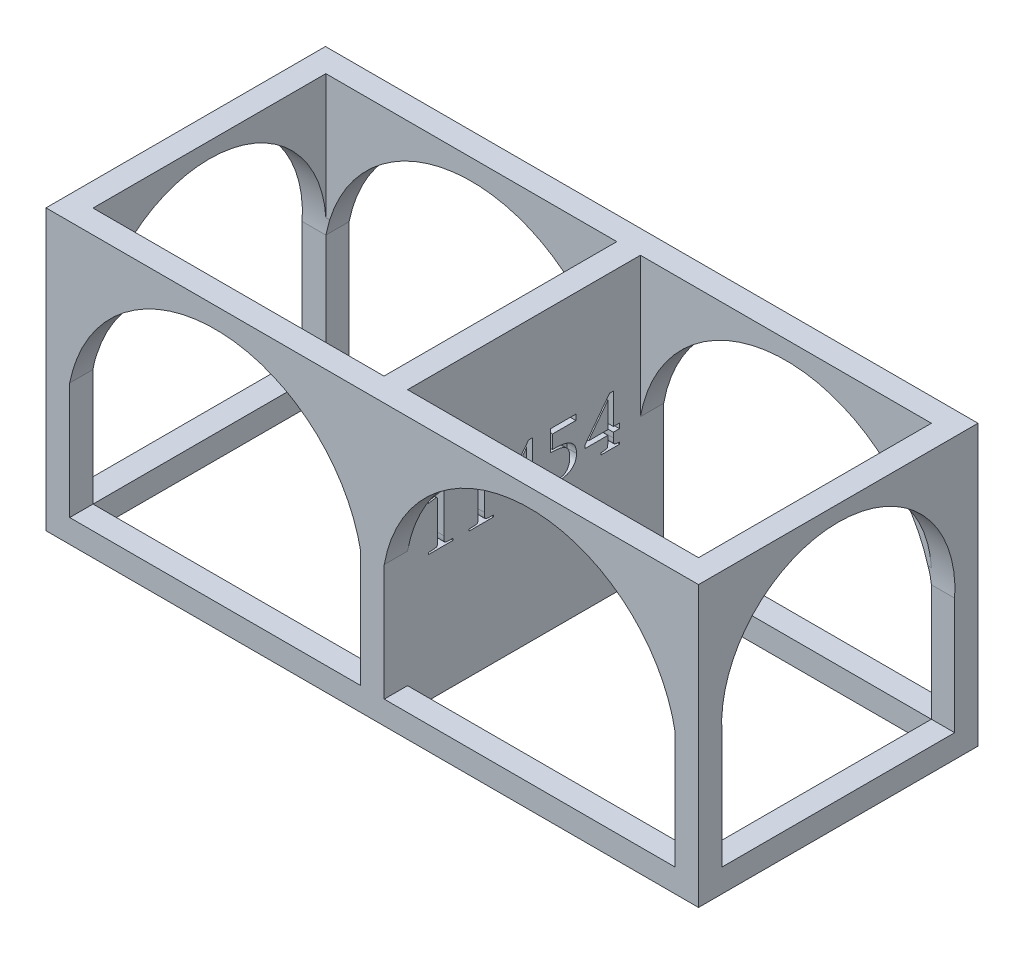
from build123d import *

# Parameters (mm, degrees)
SKETCH1_W            = 177.8
SKETCH1_H            = 6.35
BOSS_EXTRUDE1_DEPTH  = 6.35
SKETCH2_W            = 6.35
SKETCH2_H            = 76.149234203
BOSS_EXTRUDE3_DEPTH  = 6.35
SKETCH3_W            = 177.8
SKETCH3_H            = 6.35
BOSS_EXTRUDE4_DEPTH  = 6.35
SKETCH4_W            = 6.453896743
SKETCH4_H            = 76.149234203
BOSS_EXTRUDE5_DEPTH  = 6.35
SKETCH5_W            = 6.421405537
SKETCH5_H            = 76.149234203
BOSS_EXTRUDE6_DEPTH  = 76.2
SKETCH6_W            = 6.453896743
SKETCH6_H            = 6.35
BOSS_EXTRUDE7_DEPTH  = 76.2
SKETCH7_W            = 6.453896743
SKETCH7_H            = 6.35
BOSS_EXTRUDE8_DEPTH  = 76.2
SKETCH8_W            = 6.35
SKETCH8_H            = 6.35
BOSS_EXTRUDE9_DEPTH  = 76.2
SKETCH9_W            = 6.35
SKETCH9_H            = 6.35
BOSS_EXTRUDE10_DEPTH = 76.2
SKETCH10_W           = 6.453896743
SKETCH10_H           = 76.149234203
BOSS_EXTRUDE11_DEPTH = 6.35
SKETCH11_W           = 6.35
SKETCH11_H           = 76.149234203
BOSS_EXTRUDE12_DEPTH = 6.35
SKETCH12_W           = 165.323674895
SKETCH12_H           = 6.35
BOSS_EXTRUDE13_DEPTH = 6.35
SKETCH13_W           = 6.35
SKETCH13_H           = 6.35
BOSS_EXTRUDE14_DEPTH = 175.26
CUT_EXTRUDE1_DEPTH   = 2.54
SKETCH22_W           = 6.35
SKETCH22_H           = 31.75
BOSS_EXTRUDE16_DEPTH = 165.1
CUT_EXTRUDE3_DEPTH   = 165.1
CUT_EXTRUDE4_DEPTH   = 165.1
SKETCH26_W           = 6.35
SKETCH26_H           = 31.75
BOSS_EXTRUDE17_DEPTH = 165.1
CUT_EXTRUDE5_DEPTH   = 165.1
CUT_EXTRUDE6_DEPTH   = 165.1
SKETCH29_W           = 6.453896743
SKETCH29_H           = 31.75
BOSS_EXTRUDE18_DEPTH = 65.278
CUT_EXTRUDE7_DEPTH   = 65.278
SKETCH31_W           = 6.35
SKETCH31_H           = 31.75
BOSS_EXTRUDE19_DEPTH = 65.278
CUT_EXTRUDE8_DEPTH   = 65.278


with BuildPart() as part:
    # Sketch1 → Boss-Extrude1 (new body)
    with BuildSketch(Plane(origin=(0, 0, 0), x_dir=(1, 0, 0), z_dir=(0, 1, 0))):
        with Locations((88.9, -3.175)):
            Rectangle(SKETCH1_W, SKETCH1_H)
    extrude(amount=BOSS_EXTRUDE1_DEPTH)

    # Sketch2 → Boss-Extrude3 (add)
    with BuildSketch(Plane(origin=(0, 0, 0), x_dir=(-1, 0, 0), z_dir=(0, -1, 0))):
        with Locations((-174.625, -38.074617102)):
            Rectangle(SKETCH2_W, SKETCH2_H)
    extrude(amount=-BOSS_EXTRUDE3_DEPTH)

    # Sketch3 → Boss-Extrude4 (add)
    with BuildSketch(Plane.XZ):
        with Locations((88.9, 72.974234203)):
            Rectangle(SKETCH3_W, SKETCH3_H)
    extrude(amount=-BOSS_EXTRUDE4_DEPTH)

    # Sketch4 → Boss-Extrude5 (add)
    with BuildSketch(Plane(origin=(0, 0, 0), x_dir=(-1, 0, 0), z_dir=(0, -1, 0))):
        with Locations((-3.226948372, -38.074617102)):
            Rectangle(SKETCH4_W, SKETCH4_H)
    extrude(amount=-BOSS_EXTRUDE5_DEPTH)

    # Sketch5 → Boss-Extrude6 (add)
    with BuildSketch(Plane(origin=(0, 0, 0), x_dir=(-1, 0, 0), z_dir=(0, -1, 0))):
        with Locations((-88.951948372, -38.074617102)):
            Rectangle(SKETCH5_W, SKETCH5_H)
    extrude(amount=-BOSS_EXTRUDE6_DEPTH)

    # Sketch6 → Boss-Extrude7 (add)
    with BuildSketch(Plane(origin=(0, 0, 0), x_dir=(-1, 0, 0), z_dir=(0, -1, 0))):
        with Locations((-3.226948372, -72.974234203)):
            Rectangle(SKETCH6_W, SKETCH6_H)
    extrude(amount=-BOSS_EXTRUDE7_DEPTH)

    # Sketch7 → Boss-Extrude8 (add)
    with BuildSketch(Plane(origin=(0, 0, 0), x_dir=(-1, 0, 0), z_dir=(0, -1, 0))):
        with Locations((-3.226948372, -3.175)):
            Rectangle(SKETCH7_W, SKETCH7_H)
    extrude(amount=-BOSS_EXTRUDE8_DEPTH)

    # Sketch8 → Boss-Extrude9 (add)
    with BuildSketch(Plane(origin=(0, 0, 0), x_dir=(-1, 0, 0), z_dir=(0, -1, 0))):
        with Locations((-174.625, -3.175)):
            Rectangle(SKETCH8_W, SKETCH8_H)
    extrude(amount=-BOSS_EXTRUDE9_DEPTH)

    # Sketch9 → Boss-Extrude10 (add)
    with BuildSketch(Plane(origin=(0, 0, 0), x_dir=(-1, 0, 0), z_dir=(0, -1, 0))):
        with Locations((-174.625, -72.974234203)):
            Rectangle(SKETCH9_W, SKETCH9_H)
    extrude(amount=-BOSS_EXTRUDE10_DEPTH)

    # Sketch10 → Boss-Extrude11 (add)
    with BuildSketch(Plane(origin=(0, 76.2, 0), x_dir=(1, 0, 0), z_dir=(0, 1, 0))):
        with Locations((3.226948372, -38.074617102)):
            Rectangle(SKETCH10_W, SKETCH10_H)
    extrude(amount=-BOSS_EXTRUDE11_DEPTH)

    # Sketch11 → Boss-Extrude12 (add)
    with BuildSketch(Plane(origin=(0, 76.2, 0), x_dir=(1, 0, 0), z_dir=(0, 1, 0))):
        with Locations((174.625, -38.074617102)):
            Rectangle(SKETCH11_W, SKETCH11_H)
    extrude(amount=-BOSS_EXTRUDE12_DEPTH)

    # Sketch12 → Boss-Extrude13 (add)
    with BuildSketch(Plane(origin=(0, 69.85, 0), x_dir=(-1, 0, 0), z_dir=(0, -1, 0))):
        with Locations((-89.115734191, -3.175)):
            Rectangle(SKETCH12_W, SKETCH12_H)
    extrude(amount=-BOSS_EXTRUDE13_DEPTH)

    # Sketch13 → Boss-Extrude14 (add)
    with BuildSketch(Plane.ZY):
        with Locations((72.974234203, 73.025)):
            Rectangle(SKETCH13_W, SKETCH13_H)
    extrude(amount=-BOSS_EXTRUDE14_DEPTH)

    # Sketch16 → Cut-Extrude1 (cut)
    with BuildSketch(Plane(origin=(92.16265114, 0, 0), x_dir=(0, 0, -1), z_dir=(1, 0, 0))):
        with BuildLine():
            Line((-59.914633961, 47.83491605), (-59.914633961, 36.787925866))
            add(Edge.make_bspline(
                [(-59.914633961, 36.787925866), (-59.913759787, 36.663245095), (-59.912120669, 36.429462827), (-59.896980538, 36.102264714), (-59.871643151, 35.821080582), (-59.837275502, 35.586583277), (-59.791150313, 35.39723477), (-59.736881528, 35.255133097), (-59.669883586, 35.151064291), (-59.607603225, 35.12008517), (-59.579876683, 35.106293601)],
                knots=[0, 0, 0, 0, 0.000374023, 0.000701311, 0.000982367, 0.001220574, 0.001412134, 0.00156463, 0.001678658, 0.001770156, 0.001770156, 0.001770156, 0.001770156], degree=3))
            add(Edge.make_bspline(
                [(-59.579876683, 35.106293601), (-59.392401179, 35.062488157), (-59.016424865, 34.974637698), (-58.630488719, 34.963037777), (-58.436994412, 34.957222)],
                knots=[0, 0, 0, 0, 0.000575988, 0.001155126, 0.001155126, 0.001155126, 0.001155126], degree=3))
            Line((-58.436994412, 34.957222), (-57.403954374, 34.946760835))
            Line((-57.403954374, 34.946760835), (-57.403954374, 34.444624918))
            Line((-57.403954374, 34.444624918), (-64.09909994, 34.444624918))
            Line((-64.09909994, 34.444624918), (-64.09909994, 34.946760835))
            Line((-64.09909994, 34.946760835), (-63.066059902, 34.957222))
            add(Edge.make_bspline(
                [(-63.066059902, 34.957222), (-62.872565595, 34.963037777), (-62.486629449, 34.974637698), (-62.110653135, 35.062488157), (-61.923177631, 35.106293601)],
                knots=[0, 0, 0, 0, 0.000579138, 0.001155126, 0.001155126, 0.001155126, 0.001155126], degree=3))
            add(Edge.make_bspline(
                [(-61.923177631, 35.106293601), (-61.895451089, 35.12008517), (-61.833170729, 35.151064291), (-61.766172786, 35.255133097), (-61.711904001, 35.39723477), (-61.665778812, 35.586583277), (-61.631411163, 35.821080582), (-61.606073777, 36.102264714), (-61.590933646, 36.429462827), (-61.589294527, 36.663245095), (-61.588420353, 36.787925866)],
                knots=[0, 0, 0, 0, 9.1498e-05, 0.000205526, 0.000358022, 0.000549582, 0.000787789, 0.001068845, 0.001396132, 0.001770156, 0.001770156, 0.001770156, 0.001770156], degree=3))
            Line((-61.588420353, 36.787925866), (-61.588420353, 45.279776512))
            add(Edge.make_bspline(
                [(-61.588420353, 45.279776512), (-61.58905978, 45.412300604), (-61.590234229, 45.655710533), (-61.607169163, 45.98930044), (-61.637519326, 46.258371421), (-61.676011963, 46.469249407), (-61.733690952, 46.627694028), (-61.805299758, 46.7429507), (-61.900887104, 46.819755862), (-61.975153769, 46.827027138), (-62.012097533, 46.830644215)],
                knots=[0, 0, 0, 0, 0.000397559, 0.000730205, 0.001001402, 0.001209642, 0.001371874, 0.001503888, 0.001614259, 0.001723508, 0.001723508, 0.001723508, 0.001723508], degree=3))
            add(Edge.make_bspline(
                [(-62.012097533, 46.830644215), (-62.038264027, 46.830024184), (-62.097659418, 46.828616774), (-62.197038193, 46.819719959), (-62.317608729, 46.807532713), (-62.458295729, 46.784293092), (-62.621063908, 46.763057647), (-62.802623968, 46.729397475), (-63.00631847, 46.696981341), (-63.148078908, 46.669787462), (-63.222977376, 46.655419703)],
                knots=[0, 0, 0, 0, 7.8502e-05, 0.000178193, 0.000299205, 0.000441972, 0.000605819, 0.00079156, 0.000995787, 0.001224562, 0.001224562, 0.001224562, 0.001224562], degree=3))
            Line((-63.222977376, 46.655419703), (-64.09909994, 46.495886937))
            Line((-64.09909994, 46.495886937), (-64.09909994, 46.998022855))
            Line((-64.09909994, 46.998022855), (-59.914633961, 47.83491605))
        make_face()
        with BuildLine():
            Line((-48.867643777, 47.83491605), (-48.867643777, 36.787925866))
            add(Edge.make_bspline(
                [(-48.867643777, 36.787925866), (-48.866769602, 36.663245095), (-48.865130484, 36.429462827), (-48.849990353, 36.102264714), (-48.824652967, 35.821080582), (-48.790285317, 35.586583277), (-48.744160129, 35.39723477), (-48.689891344, 35.255133097), (-48.622893401, 35.151064291), (-48.56061304, 35.12008517), (-48.532886499, 35.106293601)],
                knots=[0, 0, 0, 0, 0.000374023, 0.000701311, 0.000982367, 0.001220574, 0.001412134, 0.00156463, 0.001678658, 0.001770156, 0.001770156, 0.001770156, 0.001770156], degree=3))
            add(Edge.make_bspline(
                [(-48.532886499, 35.106293601), (-48.345410995, 35.062488157), (-47.969434681, 34.974637698), (-47.583498535, 34.963037777), (-47.390004228, 34.957222)],
                knots=[0, 0, 0, 0, 0.000575988, 0.001155126, 0.001155126, 0.001155126, 0.001155126], degree=3))
            Line((-47.390004228, 34.957222), (-46.35696419, 34.946760835))
            Line((-46.35696419, 34.946760835), (-46.35696419, 34.444624918))
            Line((-46.35696419, 34.444624918), (-53.052109756, 34.444624918))
            Line((-53.052109756, 34.444624918), (-53.052109756, 34.946760835))
            Line((-53.052109756, 34.946760835), (-52.019069717, 34.957222))
            add(Edge.make_bspline(
                [(-52.019069717, 34.957222), (-51.825575411, 34.963037777), (-51.439639264, 34.974637698), (-51.063662951, 35.062488157), (-50.876187447, 35.106293601)],
                knots=[0, 0, 0, 0, 0.000579138, 0.001155126, 0.001155126, 0.001155126, 0.001155126], degree=3))
            add(Edge.make_bspline(
                [(-50.876187447, 35.106293601), (-50.848460905, 35.12008517), (-50.786180544, 35.151064291), (-50.719182602, 35.255133097), (-50.664913817, 35.39723477), (-50.618788628, 35.586583277), (-50.584420979, 35.821080582), (-50.559083592, 36.102264714), (-50.543943461, 36.429462827), (-50.542304343, 36.663245095), (-50.541430169, 36.787925866)],
                knots=[0, 0, 0, 0, 9.1498e-05, 0.000205526, 0.000358022, 0.000549582, 0.000787789, 0.001068845, 0.001396132, 0.001770156, 0.001770156, 0.001770156, 0.001770156], degree=3))
            Line((-50.541430169, 36.787925866), (-50.541430169, 45.279776512))
            add(Edge.make_bspline(
                [(-50.541430169, 45.279776512), (-50.542069595, 45.412300604), (-50.543244045, 45.655710533), (-50.560178978, 45.98930044), (-50.590529141, 46.258371421), (-50.629021779, 46.469249407), (-50.686700768, 46.627694028), (-50.758309574, 46.7429507), (-50.85389692, 46.819755862), (-50.928163585, 46.827027138), (-50.965107349, 46.830644215)],
                knots=[0, 0, 0, 0, 0.000397559, 0.000730205, 0.001001402, 0.001209642, 0.001371874, 0.001503888, 0.001614259, 0.001723508, 0.001723508, 0.001723508, 0.001723508], degree=3))
            add(Edge.make_bspline(
                [(-50.965107349, 46.830644215), (-50.991273842, 46.830024184), (-51.050669234, 46.828616774), (-51.150048009, 46.819719959), (-51.270618545, 46.807532713), (-51.411305544, 46.784293092), (-51.574073724, 46.763057647), (-51.755633784, 46.729397475), (-51.959328286, 46.696981341), (-52.101088723, 46.669787462), (-52.175987192, 46.655419703)],
                knots=[0, 0, 0, 0, 7.8502e-05, 0.000178193, 0.000299205, 0.000441972, 0.000605819, 0.00079156, 0.000995787, 0.001224562, 0.001224562, 0.001224562, 0.001224562], degree=3))
            Line((-52.175987192, 46.655419703), (-53.052109756, 46.495886937))
            Line((-53.052109756, 46.495886937), (-53.052109756, 46.998022855))
            Line((-53.052109756, 46.998022855), (-48.867643777, 47.83491605))
        make_face()
        with BuildLine():
            Line((-37.318517675, 38.126954979), (-43.511527324, 38.126954979))
            Line((-43.511527324, 38.126954979), (-43.511527324, 39.016154))
            Line((-43.511527324, 39.016154), (-36.834688796, 47.83491605))
            Line((-36.834688796, 47.83491605), (-35.812109923, 47.83491605))
            Line((-35.812109923, 47.83491605), (-35.812109923, 39.465984093))
            Line((-35.812109923, 39.465984093), (-34.138323531, 39.465984093))
            Line((-34.138323531, 39.465984093), (-34.138323531, 38.126954979))
            Line((-34.138323531, 38.126954979), (-35.812109923, 38.126954979))
            Line((-35.812109923, 38.126954979), (-35.812109923, 36.787925866))
            add(Edge.make_bspline(
                [(-35.812109923, 36.787925866), (-35.811925803, 36.687660934), (-35.811576658, 36.497529202), (-35.800561224, 36.228073269), (-35.785341528, 35.990846704), (-35.765937635, 35.785468718), (-35.737233937, 35.612591204), (-35.704598987, 35.471402477), (-35.667206811, 35.360957906), (-35.617740037, 35.27711367), (-35.546618739, 35.213585604), (-35.450662, 35.164209137), (-35.328098398, 35.116303462), (-35.176543024, 35.077534792), (-34.998351086, 35.036357232), (-34.790693954, 35.007985812), (-34.555528369, 34.977829615), (-34.388599154, 34.964342372), (-34.300471588, 34.957222)],
                knots=[0, 0, 0, 0, 0.00030077, 0.000570348, 0.000808856, 0.001013919, 0.001188909, 0.00133417, 0.001448347, 0.001537613, 0.001622761, 0.001730465, 0.001859651, 0.002017003, 0.002199119, 0.002408097, 0.002645224, 0.002910415, 0.002910415, 0.002910415, 0.002910415], degree=3))
            Line((-34.300471588, 34.957222), (-34.138323531, 34.946760835))
            Line((-34.138323531, 34.946760835), (-34.138323531, 34.444624918))
            Line((-34.138323531, 34.444624918), (-39.159682706, 34.444624918))
            Line((-39.159682706, 34.444624918), (-39.159682706, 34.946760835))
            Line((-39.159682706, 34.946760835), (-39.002765232, 34.957222))
            add(Edge.make_bspline(
                [(-39.002765232, 34.957222), (-38.899858841, 34.964627249), (-38.705235248, 34.978632562), (-38.430622754, 35.005121311), (-38.190362897, 35.031869136), (-37.985583709, 35.066774859), (-37.815388252, 35.100849838), (-37.68039367, 35.14258918), (-37.579677722, 35.185563247), (-37.501988131, 35.235344675), (-37.455094454, 35.316015904), (-37.417617753, 35.421160561), (-37.387748913, 35.563027844), (-37.363002091, 35.73865047), (-37.342324966, 35.950711131), (-37.326748935, 36.197527443), (-37.320005996, 36.481027586), (-37.319033458, 36.681569203), (-37.318517675, 36.787925866)],
                knots=[0, 0, 0, 0, 0.000309501, 0.000585349, 0.000827669, 0.001034476, 0.001208368, 0.001348158, 0.001457031, 0.001537597, 0.00161884, 0.001730565, 0.001872684, 0.002052436, 0.002262703, 0.002511651, 0.002794211, 0.003113287, 0.003113287, 0.003113287, 0.003113287], degree=3))
            Line((-37.318517675, 36.787925866), (-37.318517675, 38.126954979))
        make_face()
        Polygon((-42.575253061, 39.465984093), (-37.318517675, 39.465984093), (-37.318517675, 46.406967035), align=None, mode=Mode.SUBTRACT)
        with BuildLine():
            Line((-30.958129387, 34.444624918), (-30.958129387, 36.620547227))
            Line((-30.958129387, 36.620547227), (-30.121236192, 36.620547227))
            Line((-30.121236192, 36.620547227), (-30.121236192, 36.403478054))
            add(Edge.make_bspline(
                [(-30.121236192, 36.403478054), (-30.120564631, 36.318876102), (-30.119275124, 36.156426499), (-30.100429889, 35.924208555), (-30.072060001, 35.712783095), (-30.033574649, 35.522997354), (-29.985740551, 35.353674702), (-29.921015233, 35.208184598), (-29.850105087, 35.080718429), (-29.760199137, 34.975601418), (-29.655500936, 34.886676314), (-29.529352334, 34.813202244), (-29.382222052, 34.751531849), (-29.215063891, 34.699353277), (-29.026589457, 34.66083959), (-28.816883314, 34.63284561), (-28.58552706, 34.614022339), (-28.423951726, 34.612692621), (-28.340222859, 34.612003557)],
                knots=[0, 0, 0, 0, 0.000253737, 0.000487217, 0.000698409, 0.000893314, 0.001067913, 0.001224852, 0.001370183, 0.001503793, 0.001637404, 0.001780482, 0.001939822, 0.002115183, 0.002304967, 0.002516159, 0.002749639, 0.003000761, 0.003000761, 0.003000761, 0.003000761], degree=3))
            add(Edge.make_bspline(
                [(-28.340222859, 34.612003557), (-28.237199735, 34.615133927), (-28.035399548, 34.62126565), (-27.741240656, 34.665836359), (-27.463579822, 34.741755291), (-27.203454229, 34.850397979), (-26.957976795, 34.986078264), (-26.731355363, 35.156164994), (-26.521735653, 35.355537201), (-26.331116162, 35.584637105), (-26.158145874, 35.837910466), (-26.00928546, 36.116260918), (-25.884529454, 36.416358643), (-25.777944794, 36.736460123), (-25.70193463, 37.080419271), (-25.644673345, 37.445479714), (-25.606246078, 37.832357139), (-25.603446615, 38.09809192), (-25.602012934, 38.23418192)],
                knots=[0, 0, 0, 0, 0.000309003, 0.000605271, 0.000890157, 0.001170397, 0.001449057, 0.001729418, 0.002018002, 0.002315019, 0.002621857, 0.002936616, 0.00326011, 0.003595887, 0.00394736, 0.00431541, 0.004704201, 0.005112321, 0.005112321, 0.005112321, 0.005112321], degree=3))
            add(Edge.make_bspline(
                [(-25.602012934, 38.23418192), (-25.605215808, 38.393887983), (-25.611397098, 38.702107842), (-25.667191224, 39.145060661), (-25.755262972, 39.55187242), (-25.877824601, 39.922762497), (-26.046243739, 40.253349079), (-26.244267012, 40.548907282), (-26.480606809, 40.807369651), (-26.758290177, 41.027752631), (-27.081941445, 41.214357106), (-27.453698102, 41.376715916), (-27.879252976, 41.510656651), (-28.358800373, 41.619385261), (-28.890996971, 41.703526281), (-29.476614431, 41.766234878), (-30.115565222, 41.801738481), (-30.559689396, 41.806702464), (-30.790750748, 41.809285041)],
                knots=[0, 0, 0, 0, 0.000478948, 0.000924332, 0.001336786, 0.001726324, 0.002092408, 0.002446392, 0.002790678, 0.003138669, 0.003505574, 0.003908406, 0.004353374, 0.004841867, 0.005382322, 0.0059689, 0.00660808, 0.007301256, 0.007301256, 0.007301256, 0.007301256], degree=3))
            Line((-30.790750748, 41.809285041), (-30.790750748, 47.500158772))
            Line((-30.790750748, 47.500158772), (-23.928226543, 47.500158772))
            Line((-23.928226543, 47.500158772), (-23.928226543, 45.99375102))
            Line((-23.928226543, 45.99375102), (-30.288614831, 45.99375102))
            Line((-30.288614831, 45.99375102), (-30.288614831, 42.311420958))
            Line((-30.288614831, 42.311420958), (-29.449106344, 42.311420958))
            add(Edge.make_bspline(
                [(-29.449106344, 42.311420958), (-29.219728242, 42.308856857), (-28.774346395, 42.303878161), (-28.129182963, 42.252843513), (-27.527735774, 42.174304361), (-26.971204277, 42.058710836), (-26.458007523, 41.914321773), (-25.988363412, 41.735999703), (-25.562392638, 41.525909255), (-25.183172135, 41.277088346), (-24.844244741, 41.00078204), (-24.555457203, 40.685050732), (-24.305469824, 40.341302036), (-24.107988338, 39.959974262), (-23.948008178, 39.549489841), (-23.841533831, 39.103275203), (-23.770421839, 38.626151765), (-23.764096759, 38.2963543), (-23.760847904, 38.126954979)],
                knots=[0, 0, 0, 0, 0.000688001, 0.001335886, 0.00194025, 0.002506508, 0.003039617, 0.003537951, 0.004011637, 0.004461376, 0.004896018, 0.005319832, 0.005741511, 0.006167346, 0.006604467, 0.007059896, 0.007540712, 0.008048509, 0.008048509, 0.008048509, 0.008048509], degree=3))
            add(Edge.make_bspline(
                [(-23.760847904, 38.126954979), (-23.764861082, 37.974186691), (-23.772713403, 37.675275052), (-23.834180758, 37.239881108), (-23.932175784, 36.828920314), (-24.074030632, 36.444157328), (-24.258343281, 36.086291908), (-24.483035059, 35.754327417), (-24.74575046, 35.445858337), (-25.049683337, 35.167161076), (-25.389128779, 34.917447349), (-25.761179285, 34.700869868), (-26.163381904, 34.517264593), (-26.596276821, 34.368167599), (-27.059850931, 34.250609427), (-27.554977424, 34.168425507), (-28.080239539, 34.117620554), (-28.440355379, 34.112498185), (-28.625289604, 34.10986764)],
                knots=[0, 0, 0, 0, 0.000458154, 0.00089644, 0.001316355, 0.001723467, 0.002123496, 0.002520994, 0.00292352, 0.003336247, 0.003755233, 0.004185391, 0.004625421, 0.005079496, 0.005557129, 0.006058453, 0.006583867, 0.00713853, 0.00713853, 0.00713853, 0.00713853], degree=3))
            add(Edge.make_bspline(
                [(-28.625289604, 34.10986764), (-28.814643828, 34.113907865), (-29.196977912, 34.122065675), (-29.776066928, 34.189161558), (-30.366353461, 34.291113689), (-30.759116199, 34.392999365), (-30.958129387, 34.444624918)],
                knots=[0, 0, 0, 0, 0.000567904, 0.001146681, 0.001746923, 0.002363472, 0.002363472, 0.002363472, 0.002363472], degree=3))
        make_face()
        with BuildLine():
            Line((-15.224537307, 38.126954979), (-21.417546955, 38.126954979))
            Line((-21.417546955, 38.126954979), (-21.417546955, 39.016154))
            Line((-21.417546955, 39.016154), (-14.740708428, 47.83491605))
            Line((-14.740708428, 47.83491605), (-13.718129554, 47.83491605))
            Line((-13.718129554, 47.83491605), (-13.718129554, 39.465984093))
            Line((-13.718129554, 39.465984093), (-12.044343163, 39.465984093))
            Line((-12.044343163, 39.465984093), (-12.044343163, 38.126954979))
            Line((-12.044343163, 38.126954979), (-13.718129554, 38.126954979))
            Line((-13.718129554, 38.126954979), (-13.718129554, 36.787925866))
            add(Edge.make_bspline(
                [(-13.718129554, 36.787925866), (-13.717945435, 36.687660934), (-13.71759629, 36.497529202), (-13.706580855, 36.228073269), (-13.691361159, 35.990846704), (-13.671957267, 35.785468718), (-13.643253568, 35.612591204), (-13.610618618, 35.471402477), (-13.573226442, 35.360957906), (-13.523759668, 35.27711367), (-13.452638371, 35.213585604), (-13.356681631, 35.164209137), (-13.234118029, 35.116303462), (-13.082562656, 35.077534792), (-12.904370717, 35.036357232), (-12.696713586, 35.007985812), (-12.461548, 34.977829615), (-12.294618786, 34.964342372), (-12.206491219, 34.957222)],
                knots=[0, 0, 0, 0, 0.00030077, 0.000570348, 0.000808856, 0.001013919, 0.001188909, 0.00133417, 0.001448347, 0.001537613, 0.001622761, 0.001730465, 0.001859651, 0.002017003, 0.002199119, 0.002408097, 0.002645224, 0.002910415, 0.002910415, 0.002910415, 0.002910415], degree=3))
            Line((-12.206491219, 34.957222), (-12.044343163, 34.946760835))
            Line((-12.044343163, 34.946760835), (-12.044343163, 34.444624918))
            Line((-12.044343163, 34.444624918), (-17.065702337, 34.444624918))
            Line((-17.065702337, 34.444624918), (-17.065702337, 34.946760835))
            Line((-17.065702337, 34.946760835), (-16.908784863, 34.957222))
            add(Edge.make_bspline(
                [(-16.908784863, 34.957222), (-16.805878472, 34.964627249), (-16.611254879, 34.978632562), (-16.336642386, 35.005121311), (-16.096382529, 35.031869136), (-15.891603341, 35.066774859), (-15.721407883, 35.100849838), (-15.586413301, 35.14258918), (-15.485697353, 35.185563247), (-15.408007763, 35.235344675), (-15.361114085, 35.316015904), (-15.323637385, 35.421160561), (-15.293768544, 35.563027844), (-15.269021723, 35.73865047), (-15.248344597, 35.950711131), (-15.232768566, 36.197527443), (-15.226025627, 36.481027586), (-15.225053089, 36.681569203), (-15.224537307, 36.787925866)],
                knots=[0, 0, 0, 0, 0.000309501, 0.000585349, 0.000827669, 0.001034476, 0.001208368, 0.001348158, 0.001457031, 0.001537597, 0.00161884, 0.001730565, 0.001872684, 0.002052436, 0.002262703, 0.002511651, 0.002794211, 0.003113287, 0.003113287, 0.003113287, 0.003113287], degree=3))
            Line((-15.224537307, 36.787925866), (-15.224537307, 38.126954979))
        make_face()
        Polygon((-20.481272693, 39.465984093), (-15.224537307, 39.465984093), (-15.224537307, 46.406967035), align=None, mode=Mode.SUBTRACT)
    extrude(amount=-CUT_EXTRUDE1_DEPTH, mode=Mode.SUBTRACT)

    # Sketch22 → Boss-Extrude16 (add)
    with BuildSketch(Plane(origin=(6.453896743, 0, 0), x_dir=(0, 0, -1), z_dir=(1, 0, 0))):
        with Locations((-3.175, 53.975)):
            Rectangle(SKETCH22_W, SKETCH22_H)
    extrude(amount=BOSS_EXTRUDE16_DEPTH)

    # Sketch23 → Cut-Extrude3 (cut)
    with BuildSketch(Plane(origin=(0, 0, 0), x_dir=(-1, 0, 0), z_dir=(0, 0, -1))):
        with BuildLine():
            Line((-171.45, 38.1), (-92.16265114, 38.1))
            ThreePointArc((-92.16265114, 38.1), (-131.80632557, 71.208848795), (-171.45, 38.1))
        make_face()
    extrude(amount=-CUT_EXTRUDE3_DEPTH, mode=Mode.SUBTRACT)

    # Sketch24 → Cut-Extrude4 (cut)
    with BuildSketch(Plane(origin=(0, 0, 0), x_dir=(-1, 0, 0), z_dir=(0, 0, -1))):
        with BuildLine():
            Line((-85.741245603, 38.1), (-6.453896743, 38.1))
            ThreePointArc((-6.453896743, 38.1), (-46.097571173, 70.631447486), (-85.741245603, 38.1))
        make_face()
    extrude(amount=-CUT_EXTRUDE4_DEPTH, mode=Mode.SUBTRACT)

    # Sketch26 → Boss-Extrude17 (add)
    with BuildSketch(Plane.ZY.offset(-171.45)):
        with Locations((72.974234203, 53.975)):
            Rectangle(SKETCH26_W, SKETCH26_H)
    extrude(amount=BOSS_EXTRUDE17_DEPTH)

    # Sketch27 → Cut-Extrude5 (cut)
    with BuildSketch(Plane.XY.offset(76.149234203)):
        with BuildLine():
            Line((6.453896743, 38.1), (85.741245603, 38.1))
            ThreePointArc((85.741245603, 38.1), (46.097571173, 70.631447486), (6.453896743, 38.1))
        make_face()
    extrude(amount=-CUT_EXTRUDE5_DEPTH, mode=Mode.SUBTRACT)

    # Sketch28 → Cut-Extrude6 (cut)
    with BuildSketch(Plane.XY.offset(76.149234203)):
        with BuildLine():
            Line((92.16265114, 38.1), (171.45, 38.1))
            ThreePointArc((171.45, 38.1), (131.80632557, 71.208848795), (92.16265114, 38.1))
        make_face()
    extrude(amount=-CUT_EXTRUDE6_DEPTH, mode=Mode.SUBTRACT)

    # Sketch29 → Boss-Extrude18 (add)
    with BuildSketch(Plane.XY.offset(6.35)):
        with Locations((3.226948372, 53.975)):
            Rectangle(SKETCH29_W, SKETCH29_H)
    extrude(amount=BOSS_EXTRUDE18_DEPTH)

    # Sketch30 → Cut-Extrude7 (cut)
    with BuildSketch(Plane.ZY):
        with BuildLine():
            Line((6.35, 38.1), (69.799234203, 38.1))
            ThreePointArc((69.799234203, 38.1), (38.074617101, 71.962297493), (6.35, 38.1))
        make_face()
    extrude(amount=-CUT_EXTRUDE7_DEPTH, mode=Mode.SUBTRACT)

    # Sketch31 → Boss-Extrude19 (add)
    with BuildSketch(Plane(origin=(0, 0, 69.799234203), x_dir=(-1, 0, 0), z_dir=(0, 0, -1))):
        with Locations((-174.625, 53.975)):
            Rectangle(SKETCH31_W, SKETCH31_H)
    extrude(amount=BOSS_EXTRUDE19_DEPTH)

    # Sketch32 → Cut-Extrude8 (cut)
    with BuildSketch(Plane(origin=(177.8, 0, 0), x_dir=(0, 0, -1), z_dir=(1, 0, 0))):
        with BuildLine():
            Line((-69.799234203, 38.1), (-6.35, 38.1))
            ThreePointArc((-6.35, 38.1), (-38.074617101, 71.893864102), (-69.799234203, 38.1))
        make_face()
    extrude(amount=-CUT_EXTRUDE8_DEPTH, mode=Mode.SUBTRACT)


solid = part.part
